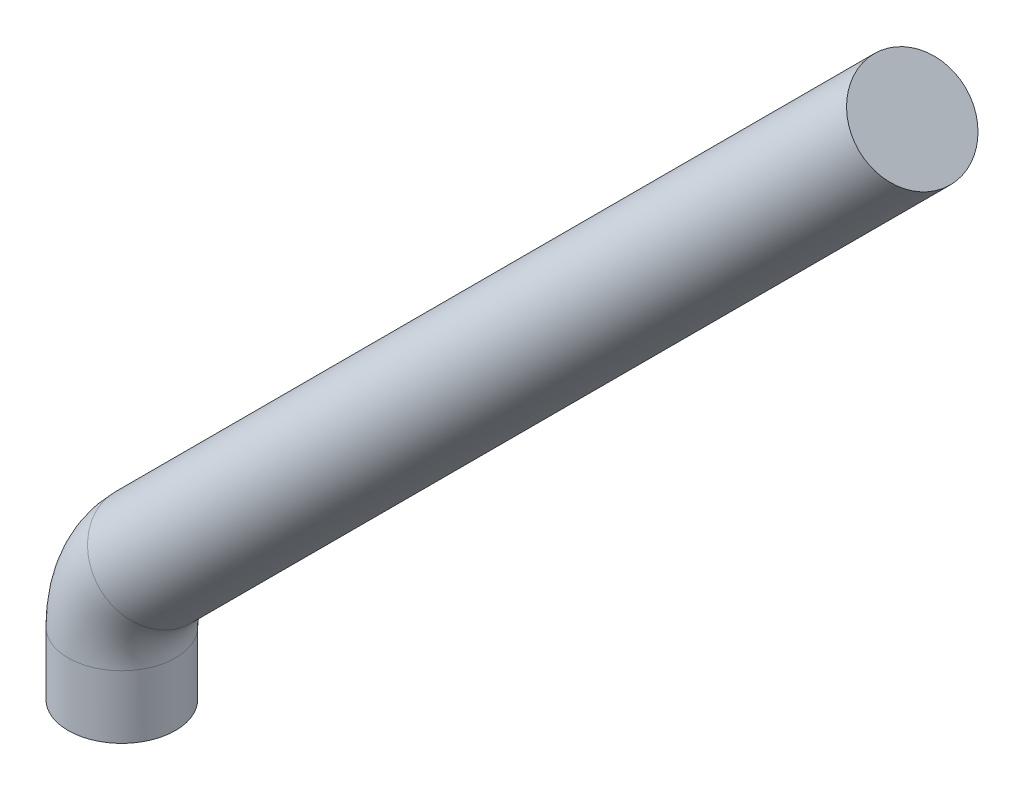
from build123d import *

# Parameters (mm, degrees)
SWEEP1_PROFILE_R = 0.127


with BuildPart() as part:
    # Sweep1: sweep along a path in Sketch2
    with BuildLine(Plane.XY) as sweep1_path:
        Line((0, 0), (0, 0.148789755))
        ThreePointArc((0, 0.148789755), (0.019334599, 0.245991347), (0.074394878, 0.328394878))
        Line((0.074394878, 0.328394878), (1.870446102, 2.124446102))
    # Sweep1 profile (on start of the path) → Sweep1 (sweep)
    with BuildSketch(Plane(origin=(0, 0, 0), x_dir=(1, 0, 0), z_dir=(0, 1, 0))):
        Circle(SWEEP1_PROFILE_R)
    sweep(path=sweep1_path.line)


solid = part.part
